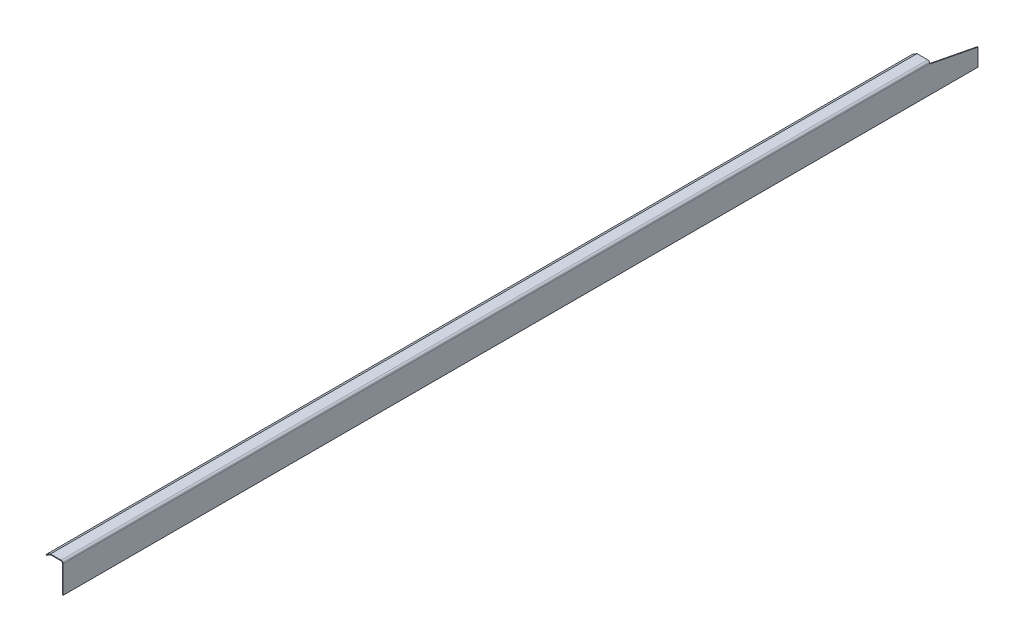
from build123d import *

# Parameters (mm, degrees)
EXTRUDE1_DEPTH     = 542.13125
CUT_EXTRUDE1_DEPTH = 25.4
CUT_EXTRUDE2_DEPTH = 25.4


with BuildPart() as part:
    # Sketch1 → Extrude1 (new body, symmetric)
    with BuildSketch(Plane.XY):
        with BuildLine():
            Line((1143, 0), (1142.20625, 0))
            Line((1142.20625, 0), (1142.20625, 32.54375))
            ThreePointArc((1142.20625, 32.54375), (1141.741282015, 33.666282015), (1140.61875, 34.13125))
            Line((1140.61875, 34.13125), (1128.140506397, 34.13125))
            Line((1128.140506397, 34.13125), (1123.091401986, 31.071186722))
            Line((1123.091401986, 31.071186722), (1122.68, 31.75))
            Line((1122.68, 31.75), (1127.91875, 34.925))
            Line((1127.91875, 34.925), (1140.61875, 34.925))
            ThreePointArc((1140.61875, 34.925), (1142.302548023, 34.227548023), (1143, 32.54375))
            Line((1143, 32.54375), (1143, 0))
        make_face()
    extrude(amount=EXTRUDE1_DEPTH, both=True)

    # Sketch2 → Cut-Extrude1 (cut)
    with BuildSketch(Plane(origin=(1143, 0, 0), x_dir=(0, 0, -1), z_dir=(1, 0, 0))):
        Polygon((542.13125, 34.925), (484.98125, 34.925), (484.98125, 31.75), (542.13125, 20.6502), align=None)
    extrude(amount=-CUT_EXTRUDE1_DEPTH, mode=Mode.SUBTRACT)

    # Sketch3 → Cut-Extrude2 (cut)
    with BuildSketch(Plane(origin=(0, 0, -484.98125), x_dir=(-1, 0, 0), z_dir=(0, 0, -1))):
        Polygon((-1127.91875, 34.925), (-1122.68, 31.75), (-1123.420434334, 30.528283348), (-1128.140506397, 34.13125), align=None)
    extrude(amount=CUT_EXTRUDE2_DEPTH, mode=Mode.SUBTRACT)


solid = part.part
